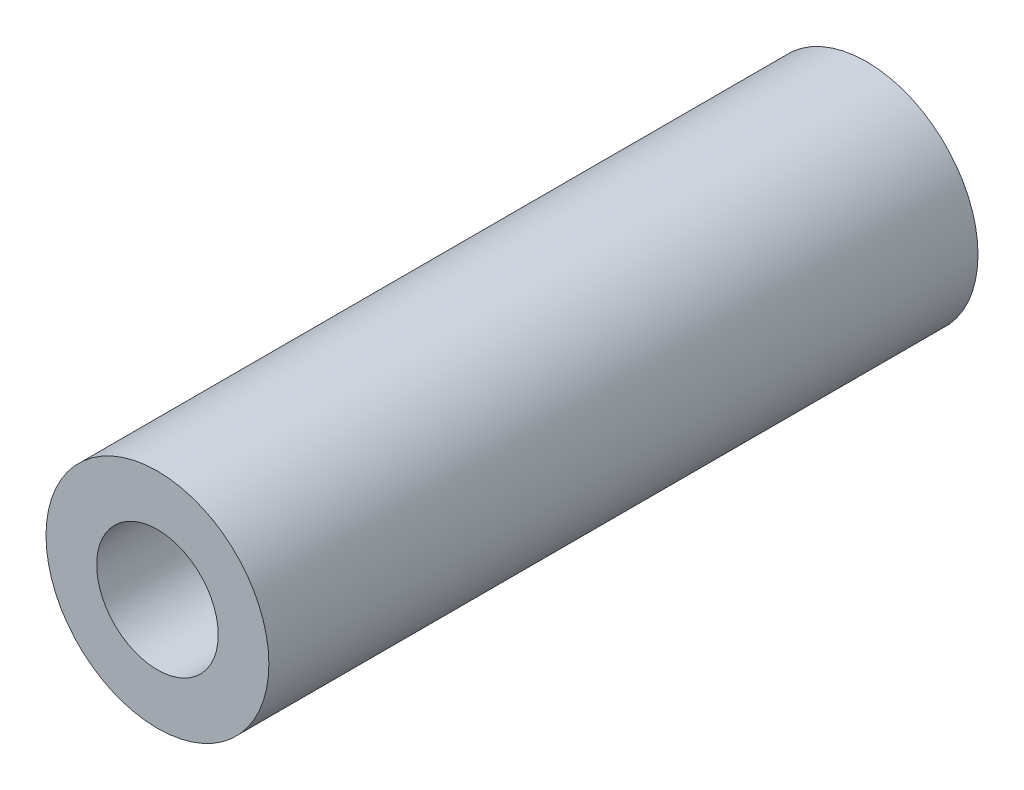
from build123d import *

# Parameters (mm, degrees)
SKETCH1_R           = 2.75
SKETCH1_R_2         = 1.5
BOSS_EXTRUDE1_DEPTH = 17.5


with BuildPart() as part:
    # Sketch1 → Boss-Extrude1 (new body)
    with BuildSketch(Plane.XY):
        Circle(SKETCH1_R)
        Circle(SKETCH1_R_2, mode=Mode.SUBTRACT)
    extrude(amount=BOSS_EXTRUDE1_DEPTH)


solid = part.part
